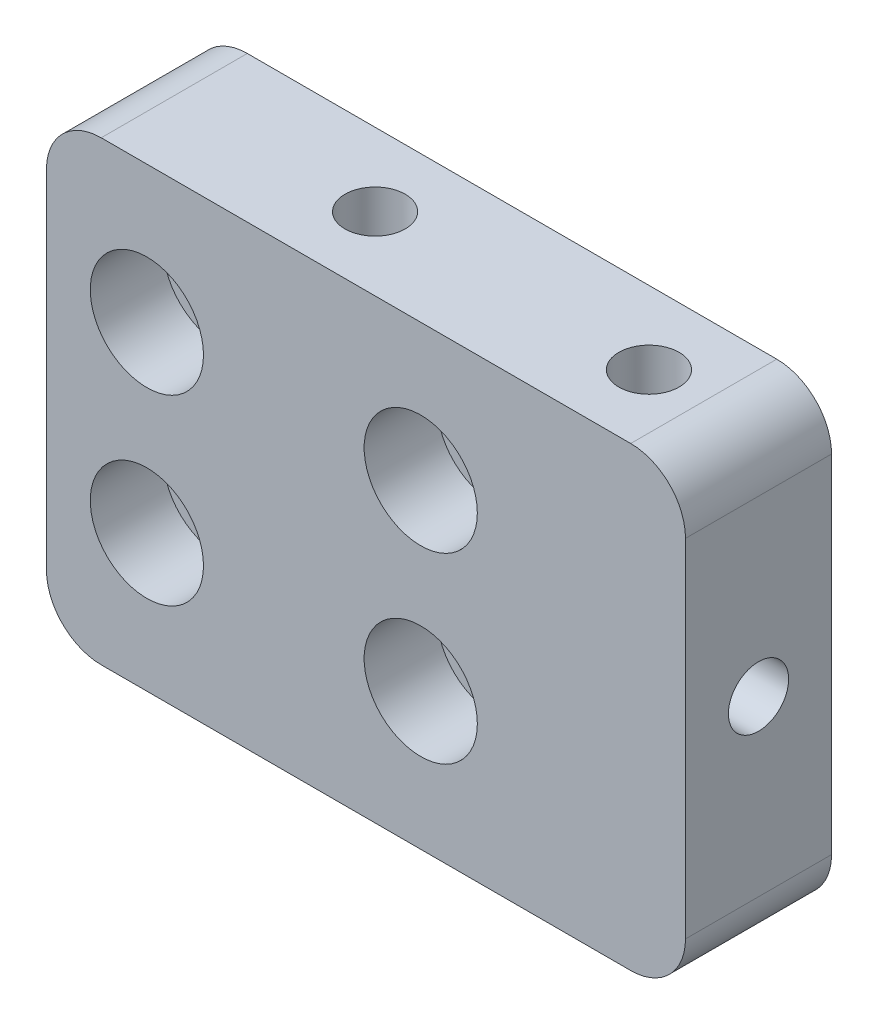
from build123d import *

# Parameters (mm, degrees)
SKETCH_1_W               = 35
SKETCH_1_H               = 25
EXTRUDE_1_DEPTH          = 8
FILLET_1_R               = 3
SKETCH_2_R               = 1.524999998
CUT_EXTRUDE_1_DEPTH      = 1
CUT_EXTRUDE_1_DEPTH_BACK = 9
SKETCH_3_R               = 3.099999998
CUT_EXTRUDE_2_DEPTH      = 4
HOLE_WIZARD_M4_1_D       = 3.3
HOLE_WIZARD_M4_2_D       = 3.3


with BuildPart() as part:
    # 草图1 → 凸台-拉伸1 (new body)
    with BuildSketch(Plane.XY):
        Rectangle(SKETCH_1_W, SKETCH_1_H)
    extrude(amount=EXTRUDE_1_DEPTH)

    # 圆角1
    fillet_1_edges = [part.edges().sort_by_distance(p)[0] for p in [
        (17.5, -12.5, 4),
        (-17.5, -12.5, 4),
        (-17.5, 12.5, 4),
        (17.5, 12.5, 4),
    ]]
    fillet(fillet_1_edges, radius=FILLET_1_R)

    # 草图2 → 切除-拉伸1 (cut, two sides)
    with BuildSketch(Plane.XY.offset(8)) as cut_extrude_1_sk:
        with Locations((3, 5.000000008)):
            Circle(SKETCH_2_R)
        with Locations((3, -4.999999992)):
            Circle(SKETCH_2_R)
        with Locations((-12, 5.000000008)):
            Circle(SKETCH_2_R)
        with Locations((-12, -4.999999992)):
            Circle(SKETCH_2_R)
    extrude(amount=CUT_EXTRUDE_1_DEPTH, mode=Mode.SUBTRACT)
    extrude(cut_extrude_1_sk.sketch, amount=-CUT_EXTRUDE_1_DEPTH_BACK, mode=Mode.SUBTRACT)

    # 草图3 → 切除-拉伸2 (cut)
    with BuildSketch(Plane.XY.offset(8)):
        with Locations((3, 5.000000008)):
            Circle(SKETCH_3_R)
        with Locations((-12, 5.000000008)):
            Circle(SKETCH_3_R)
        with Locations((3, -4.999999992)):
            Circle(SKETCH_3_R)
        with Locations((-12, -4.999999992)):
            Circle(SKETCH_3_R)
    extrude(amount=-CUT_EXTRUDE_2_DEPTH, mode=Mode.SUBTRACT)

    # M4 螺纹孔1 (through all)
    with Locations(Plane(origin=(-3.5, -12.5, 4), x_dir=(0, 0, -1), z_dir=(0, -1, 0))):
        with Locations((0, 0), (0, 15)):
            Hole(HOLE_WIZARD_M4_1_D / 2)

    # M4 螺纹孔2 (through all)
    with Locations(Plane.ZY.offset(17.5)):
        with Locations((4, 9e-09)):
            Hole(HOLE_WIZARD_M4_2_D / 2)


solid = part.part
